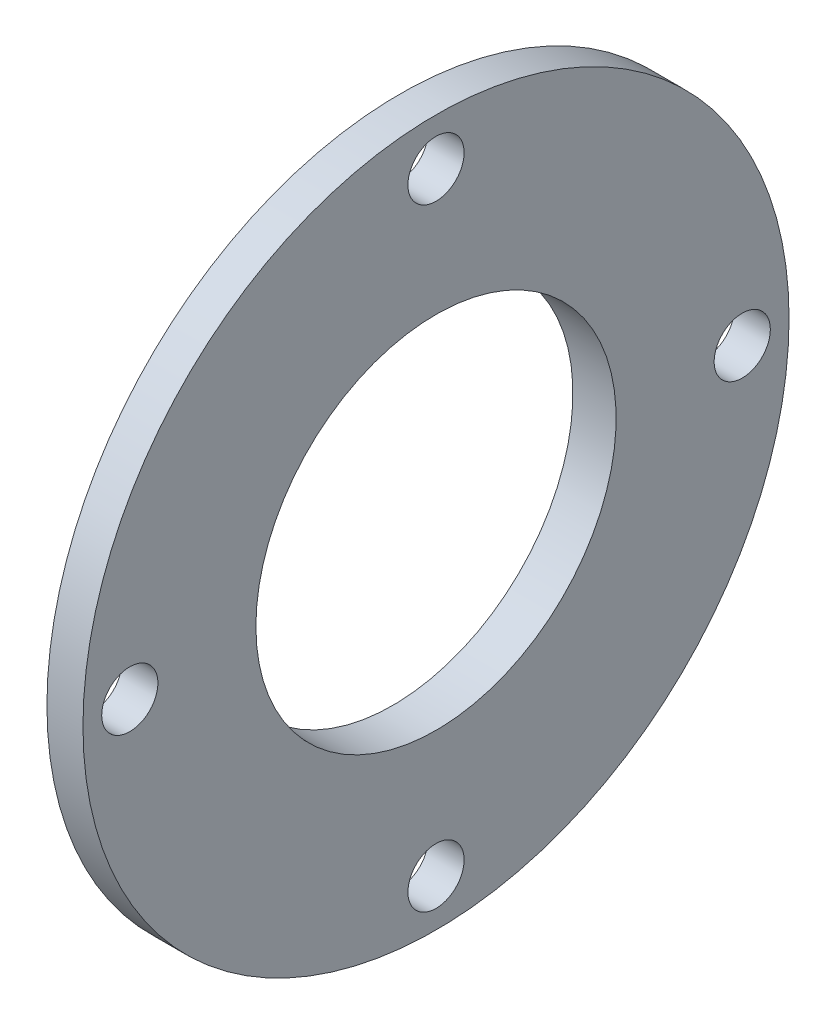
from build123d import *

# Parameters (mm, degrees)
CUT_EXTRUDE1_START = -1
SKETCH2_R          = 3.9
CUT_EXTRUDE1_DEPTH = 10
CIRPATTERN1_COUNT  = 4


with BuildPart() as part:
    # Sketch1 → Revolve1 (revolve)
    with BuildSketch(Plane.XY):
        Polygon((2, 31), (0, 31), (0, 36), (3, 36), (3, 49), (8, 49), (8, 25), (2, 25), align=None)
    revolve(axis=Axis((0, 0, 0), (1, 0, 0)))

    # Sketch2 → Cut-Extrude1 (cut)
    with BuildSketch(Plane(origin=(0, 0, 0), x_dir=(0, 0, -1), z_dir=(1, 0, 0)).offset(CUT_EXTRUDE1_START)):
        with Locations((42.5, 0)):
            Circle(SKETCH2_R)
    cut_extrude1 = extrude(amount=CUT_EXTRUDE1_DEPTH, mode=Mode.SUBTRACT)

    # CirPattern1: Cut-Extrude1 ×4 about axis
    cirpattern1_axis = Axis((0, 0, 0), (1, 0, 0))
    for i in range(1, CIRPATTERN1_COUNT):
        add(cut_extrude1.rotate(cirpattern1_axis, i * 360 / CIRPATTERN1_COUNT), mode=Mode.SUBTRACT)


solid = part.part
